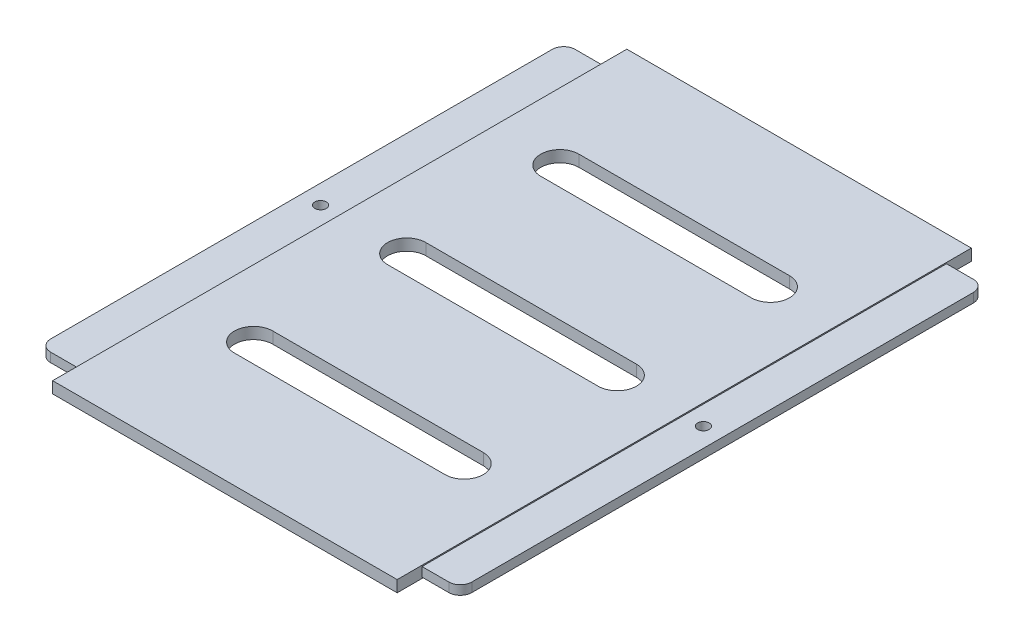
from build123d import *

# Parameters (mm, degrees)
SKETCH_1_W          = 90
SKETCH_1_H          = 150
EXTRUDE_1_DEPTH     = 3
CUT_EXTRUDE_1_DEPTH = 3
SKETCH_4_W          = 137
SKETCH_4_H          = 1.2
EXTRUDE_2_DEPTH     = 10
SKETCH_5_W          = 137
SKETCH_5_H          = 1.2
EXTRUDE_3_DEPTH     = 10
FILLET_1_R          = 3
SKETCH_6_R          = 1.5
CUT_EXTRUDE_2_DEPTH = 10
SKETCH_7_R          = 1.5
CUT_EXTRUDE_3_DEPTH = 10


with BuildPart() as part:
    # 草图1 → 凸台-拉伸1 (new body)
    with BuildSketch(Plane(origin=(0, 0, 0), x_dir=(1, 0, 0), z_dir=(0, 1, 0))):
        Rectangle(SKETCH_1_W, SKETCH_1_H)
    extrude(amount=EXTRUDE_1_DEPTH)

    # 草图2 → 切除-拉伸1 (cut)
    with BuildSketch(Plane(origin=(0, 3, 0), x_dir=(1, 0, 0), z_dir=(0, 1, 0))):
        with BuildLine():
            Line((-32.5, 40), (0, 40))
            Line((0, 40), (0, 45))
            Line((0, 45), (-27.5, 45))
            ThreePointArc((-27.5, 45), (-31.035533906, 43.535533906), (-32.5, 40))
        make_face()
        with BuildLine():
            Line((0, 45), (0, 40))
            Line((0, 40), (32.5, 40))
            ThreePointArc((32.5, 40), (31.035533906, 43.535533906), (27.5, 45))
            Line((27.5, 45), (0, 45))
        make_face()
        with BuildLine():
            Line((-27.5, 35), (0, 35))
            Line((0, 35), (0, 40))
            Line((0, 40), (-32.5, 40))
            ThreePointArc((-32.5, 40), (-31.035533906, 36.464466094), (-27.5, 35))
        make_face()
        with BuildLine():
            Line((0, 40), (0, 35))
            Line((0, 35), (27.5, 35))
            ThreePointArc((27.5, 35), (31.035533906, 36.464466094), (32.5, 40))
            Line((32.5, 40), (0, 40))
        make_face()
        with BuildLine():
            ThreePointArc((-27.5, 5), (-31.035533906, 3.535533906), (-32.5, 0))
            Line((-32.5, 0), (0, 0))
            Line((0, 0), (0, 5))
            Line((0, 5), (-27.5, 5))
        make_face()
        with BuildLine():
            Line((0, 5), (0, 0))
            Line((0, 0), (32.5, 0))
            ThreePointArc((32.5, 0), (31.035533906, 3.535533906), (27.5, 5))
            Line((27.5, 5), (0, 5))
        make_face()
        with BuildLine():
            Line((32.5, 0), (0, 0))
            Line((0, 0), (0, -5))
            Line((0, -5), (27.5, -5))
            ThreePointArc((27.5, -5), (31.035533906, -3.535533906), (32.5, 0))
        make_face()
        with BuildLine():
            Line((0, 0), (-32.5, 0))
            ThreePointArc((-32.5, 0), (-31.035533906, -3.535533906), (-27.5, -5))
            Line((-27.5, -5), (0, -5))
            Line((0, -5), (0, 0))
        make_face()
        with BuildLine():
            Line((0, -40), (0, -35))
            Line((0, -35), (-27.5, -35))
            ThreePointArc((-27.5, -35), (-31.035533906, -36.464466094), (-32.5, -40))
            Line((-32.5, -40), (0, -40))
        make_face()
        with BuildLine():
            Line((27.5, -35), (0, -35))
            Line((0, -35), (0, -40))
            Line((0, -40), (32.5, -40))
            ThreePointArc((32.5, -40), (31.035533906, -36.464466094), (27.5, -35))
        make_face()
        with BuildLine():
            Line((0, -45), (0, -40))
            Line((0, -40), (-32.5, -40))
            ThreePointArc((-32.5, -40), (-31.035533906, -43.535533906), (-27.5, -45))
            Line((-27.5, -45), (0, -45))
        make_face()
        with BuildLine():
            Line((32.5, -40), (0, -40))
            Line((0, -40), (0, -45))
            Line((0, -45), (27.5, -45))
            ThreePointArc((27.5, -45), (31.035533906, -43.535533906), (32.5, -40))
        make_face()
    extrude(amount=-CUT_EXTRUDE_1_DEPTH, mode=Mode.SUBTRACT)

    # 草图4 → 凸台-拉伸2 (add)
    with BuildSketch(Plane(origin=(45, 0, 0), x_dir=(0, 0, -1), z_dir=(1, 0, 0))):
        with Locations((0, 0.9)):
            Rectangle(SKETCH_4_W, SKETCH_4_H)
        with Locations((0, 2.1)):
            Rectangle(SKETCH_4_W, SKETCH_4_H)
    extrude(amount=EXTRUDE_2_DEPTH)

    # 草图5 → 凸台-拉伸3 (add)
    with BuildSketch(Plane.ZY.offset(45)):
        with Locations((0, 2.1)):
            Rectangle(SKETCH_5_W, SKETCH_5_H)
        with Locations((0, 0.9)):
            Rectangle(SKETCH_5_W, SKETCH_5_H)
    extrude(amount=EXTRUDE_3_DEPTH)

    # 圆角1
    fillet_1_edges = [part.edges().sort_by_distance(p)[0] for p in [
        (55, 1.5, -68.5),
        (55, 1.5, 68.5),
        (-55, 1.5, 68.5),
        (-55, 1.5, -68.5),
    ]]
    fillet(fillet_1_edges, radius=FILLET_1_R)

    # 草图6 → 切除-拉伸2 (cut)
    with BuildSketch(Plane(origin=(0, 2.7, 0), x_dir=(1, 0, 0), z_dir=(0, 1, 0))):
        with Locations((50, 0)):
            Circle(SKETCH_6_R)
    extrude(amount=-CUT_EXTRUDE_2_DEPTH, mode=Mode.SUBTRACT)

    # 草图7 → 切除-拉伸3 (cut)
    with BuildSketch(Plane(origin=(0, 2.7, 0), x_dir=(1, 0, 0), z_dir=(0, 1, 0))):
        with Locations((-50, 0)):
            Circle(SKETCH_7_R)
    extrude(amount=-CUT_EXTRUDE_3_DEPTH, mode=Mode.SUBTRACT)


solid = part.part
